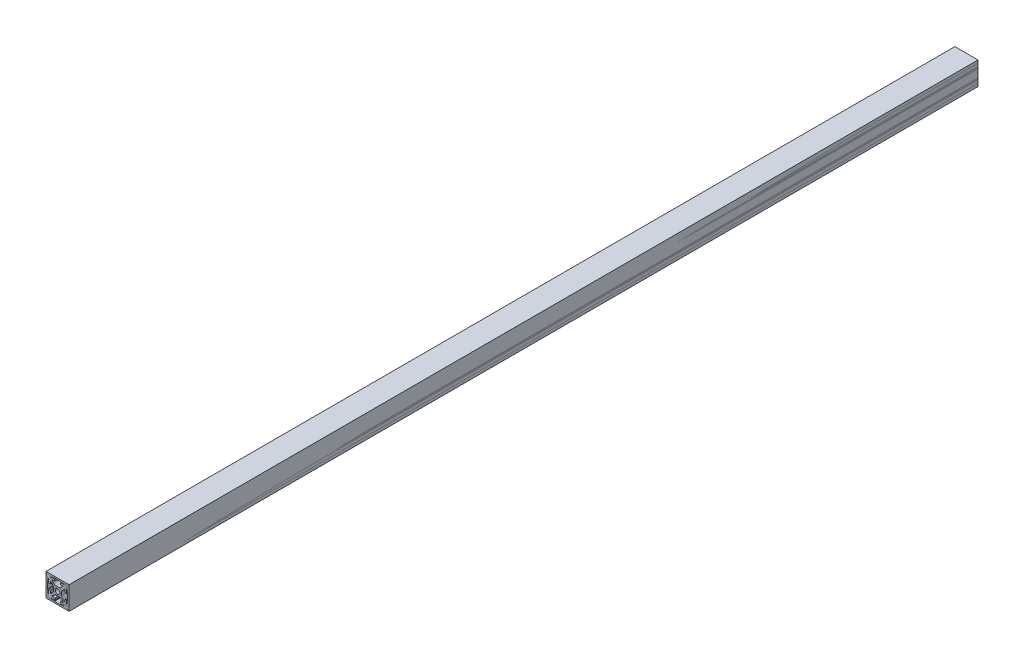
from build123d import *

# Parameters (mm, degrees)
SKETCH_2020_R       = 2.5
BOSS_EXTRUDE1_DEPTH = 1000
SKETCH2_R           = 2.6035
BOSS_EXTRUDE2_DEPTH = 1000
SKETCH3_W           = 25.4
SKETCH3_H           = 25.4
SKETCH3_W_2         = 22.225
SKETCH3_H_2         = 22.225
BOSS_EXTRUDE3_DEPTH = 1000


with BuildPart() as part:
    # 2020 → Boss-Extrude1 (new body)
    with BuildSketch(Plane.XY):
        with BuildLine():
            Line((8.25, 3), (9.75, 3))
            ThreePointArc((9.75, 3), (9.926776695, 3.073223305), (10, 3.25))
            Line((10, 3.25), (10, 9))
            ThreePointArc((10, 9), (9.707106781, 9.707106781), (9, 10))
            Line((9, 10), (3.25, 10))
            ThreePointArc((3.25, 10), (3.073223305, 9.926776695), (3, 9.75))
            Line((3, 9.75), (3, 8.25))
            ThreePointArc((3, 8.25), (3.073223305, 8.073223305), (3.25, 8))
            Line((3.25, 8), (5.75, 8))
            ThreePointArc((5.75, 8), (5.926776695, 7.926776695), (6, 7.75))
            Line((6, 7.75), (6, 7.164213562))
            ThreePointArc((6, 7.164213562), (5.980969883, 7.068542704), (5.926776695, 6.987436867))
            Line((5.926776695, 6.987436867), (3.085786438, 4.146446609))
            ThreePointArc((3.085786438, 4.146446609), (2.923574763, 4.038060234), (2.732233047, 4))
            Line((2.732233047, 4), (-2.732233047, 4))
            ThreePointArc((-2.732233047, 4), (-2.923574763, 4.038060234), (-3.085786438, 4.146446609))
            Line((-3.085786438, 4.146446609), (-5.926776695, 6.987436867))
            ThreePointArc((-5.926776695, 6.987436867), (-5.980969883, 7.068542704), (-6, 7.164213562))
            Line((-6, 7.164213562), (-6, 7.75))
            ThreePointArc((-6, 7.75), (-5.926776695, 7.926776695), (-5.75, 8))
            Line((-5.75, 8), (-3.25, 8))
            ThreePointArc((-3.25, 8), (-3.073223305, 8.073223305), (-3, 8.25))
            Line((-3, 8.25), (-3, 9.75))
            ThreePointArc((-3, 9.75), (-3.073223305, 9.926776695), (-3.25, 10))
            Line((-3.25, 10), (-9, 10))
            ThreePointArc((-9, 10), (-9.707106781, 9.707106781), (-10, 9))
            Line((-10, 9), (-10, 3.25))
            ThreePointArc((-10, 3.25), (-9.926776695, 3.073223305), (-9.75, 3))
            Line((-9.75, 3), (-8.25, 3))
            ThreePointArc((-8.25, 3), (-8.073223305, 3.073223305), (-8, 3.25))
            Line((-8, 3.25), (-8, 5.75))
            ThreePointArc((-8, 5.75), (-7.926776695, 5.926776695), (-7.75, 6))
            Line((-7.75, 6), (-7.164213562, 6))
            ThreePointArc((-7.164213562, 6), (-7.068542704, 5.980969883), (-6.987436867, 5.926776695))
            Line((-6.987436867, 5.926776695), (-4.146446609, 3.085786438))
            ThreePointArc((-4.146446609, 3.085786438), (-4.038060234, 2.923574763), (-4, 2.732233047))
            Line((-4, 2.732233047), (-4, -2.732233047))
            ThreePointArc((-4, -2.732233047), (-4.038060234, -2.923574763), (-4.146446609, -3.085786438))
            Line((-4.146446609, -3.085786438), (-6.987436867, -5.926776695))
            ThreePointArc((-6.987436867, -5.926776695), (-7.068542704, -5.980969883), (-7.164213562, -6))
            Line((-7.164213562, -6), (-7.75, -6))
            ThreePointArc((-7.75, -6), (-7.926776695, -5.926776695), (-8, -5.75))
            Line((-8, -5.75), (-8, -3.25))
            ThreePointArc((-8, -3.25), (-8.073223305, -3.073223305), (-8.25, -3))
            Line((-8.25, -3), (-9.75, -3))
            ThreePointArc((-9.75, -3), (-9.926776695, -3.073223305), (-10, -3.25))
            Line((-10, -3.25), (-10, -9))
            ThreePointArc((-10, -9), (-9.707106781, -9.707106781), (-9, -10))
            Line((-9, -10), (-3.25, -10))
            ThreePointArc((-3.25, -10), (-3.073223305, -9.926776695), (-3, -9.75))
            Line((-3, -9.75), (-3, -8.25))
            ThreePointArc((-3, -8.25), (-3.073223305, -8.073223305), (-3.25, -8))
            Line((-3.25, -8), (-5.75, -8))
            ThreePointArc((-5.75, -8), (-5.926776695, -7.926776695), (-6, -7.75))
            Line((-6, -7.75), (-6, -7.164213562))
            ThreePointArc((-6, -7.164213562), (-5.980969883, -7.068542704), (-5.926776695, -6.987436867))
            Line((-5.926776695, -6.987436867), (-3.085786438, -4.146446609))
            ThreePointArc((-3.085786438, -4.146446609), (-2.923574763, -4.038060234), (-2.732233047, -4))
            Line((-2.732233047, -4), (2.732233047, -4))
            ThreePointArc((2.732233047, -4), (2.923574763, -4.038060234), (3.085786438, -4.146446609))
            Line((3.085786438, -4.146446609), (5.926776695, -6.987436867))
            ThreePointArc((5.926776695, -6.987436867), (5.980969883, -7.068542704), (6, -7.164213562))
            Line((6, -7.164213562), (6, -7.75))
            ThreePointArc((6, -7.75), (5.926776695, -7.926776695), (5.75, -8))
            Line((5.75, -8), (3.25, -8))
            ThreePointArc((3.25, -8), (3.073223305, -8.073223305), (3, -8.25))
            Line((3, -8.25), (3, -9.75))
            ThreePointArc((3, -9.75), (3.073223305, -9.926776695), (3.25, -10))
            Line((3.25, -10), (9, -10))
            ThreePointArc((9, -10), (9.707106781, -9.707106781), (10, -9))
            Line((10, -9), (10, -3.25))
            ThreePointArc((10, -3.25), (9.926776695, -3.073223305), (9.75, -3))
            Line((9.75, -3), (8.25, -3))
            ThreePointArc((8.25, -3), (8.073223305, -3.073223305), (8, -3.25))
            Line((8, -3.25), (8, -5.75))
            ThreePointArc((8, -5.75), (7.926776695, -5.926776695), (7.75, -6))
            Line((7.75, -6), (7.164213562, -6))
            ThreePointArc((7.164213562, -6), (7.068542704, -5.980969883), (6.987436867, -5.926776695))
            Line((6.987436867, -5.926776695), (4.146446609, -3.085786438))
            ThreePointArc((4.146446609, -3.085786438), (4.038060234, -2.923574763), (4, -2.732233047))
            Line((4, -2.732233047), (4, 2.732233047))
            ThreePointArc((4, 2.732233047), (4.038060234, 2.923574763), (4.146446609, 3.085786438))
            Line((4.146446609, 3.085786438), (6.987436867, 5.926776695))
            ThreePointArc((6.987436867, 5.926776695), (7.068542704, 5.980969883), (7.164213562, 6))
            Line((7.164213562, 6), (7.75, 6))
            ThreePointArc((7.75, 6), (7.926776695, 5.926776695), (8, 5.75))
            Line((8, 5.75), (8, 3.25))
            ThreePointArc((8, 3.25), (8.073223305, 3.073223305), (8.25, 3))
        make_face()
        Circle(SKETCH_2020_R, mode=Mode.SUBTRACT)
    extrude(amount=BOSS_EXTRUDE1_DEPTH)


with BuildPart() as body_2:
    # Sketch2 → Boss-Extrude2 (new body)
    with BuildSketch(Plane.XY):
        with BuildLine():
            Line((-1.709253557, -4.4958), (1.709253557, -4.4958))
            ThreePointArc((1.709253557, -4.4958), (2.922935876, -4.736928798), (3.95226937, -5.423689619))
            Line((3.95226937, -5.423689619), (7.179652728, -8.645192207))
            ThreePointArc((7.179652728, -8.645192207), (7.414733441, -9.822812921), (6.41641086, -10.4902))
            Line((6.41641086, -10.4902), (4.28752, -10.4902))
            ThreePointArc((4.28752, -10.4902), (3.545750844, -10.797450844), (3.2385, -11.53922))
            Line((3.2385, -11.53922), (3.2385, -11.65098))
            ThreePointArc((3.2385, -11.65098), (3.545750844, -12.392749156), (4.28752, -12.7))
            Line((4.28752, -12.7), (5.3171344, -12.7))
            ThreePointArc((5.3171344, -12.7), (5.8251344, -12.192), (6.3331344, -12.7))
            Line((6.3331344, -12.7), (9.5504, -12.7))
            ThreePointArc((9.5504, -12.7), (10.058323491, -12.192000006), (10.566399977, -12.699846982))
            ThreePointArc((10.566399977, -12.699846982), (12.082522516, -12.082522516), (12.699846982, -10.566399977))
            ThreePointArc((12.699846982, -10.566399977), (12.192000006, -10.058323491), (12.7, -9.5504))
            Line((12.7, -9.5504), (12.7, -6.3330836))
            ThreePointArc((12.7, -6.3330836), (12.192, -5.8250836), (12.7, -5.3170836))
            Line((12.7, -5.3170836), (12.7, -4.287470133))
            ThreePointArc((12.7, -4.287470133), (12.392749156, -3.545700977), (11.65098, -3.238450133))
            Line((11.65098, -3.238450133), (11.53922, -3.238450133))
            ThreePointArc((11.53922, -3.238450133), (10.797450844, -3.545700977), (10.4902, -4.287470133))
            Line((10.4902, -4.287470133), (10.4902, -6.402089023))
            ThreePointArc((10.4902, -6.402089023), (9.856394933, -7.351113629), (8.736962546, -7.129240479))
            Line((8.736962546, -7.129240479), (5.440484187, -3.838768792))
            ThreePointArc((5.440484187, -3.838768792), (4.75073678, -2.808015636), (4.5085, -1.591658411))
            Line((4.5085, -1.591658411), (4.5085, 1.591658411))
            ThreePointArc((4.5085, 1.591658411), (4.75073678, 2.808015636), (5.440484187, 3.838768792))
            Line((5.440484187, 3.838768792), (8.736962546, 7.129240479))
            ThreePointArc((8.736962546, 7.129240479), (9.856394933, 7.351113629), (10.4902, 6.402089023))
            Line((10.4902, 6.402089023), (10.4902, 4.287470133))
            ThreePointArc((10.4902, 4.287470133), (10.797450844, 3.545700977), (11.53922, 3.238450133))
            Line((11.53922, 3.238450133), (11.65098, 3.238450133))
            ThreePointArc((11.65098, 3.238450133), (12.392749156, 3.545700977), (12.7, 4.287470133))
            Line((12.7, 4.287470133), (12.7, 5.3171344))
            ThreePointArc((12.7, 5.3171344), (12.192, 5.8251344), (12.7, 6.3331344))
            Line((12.7, 6.3331344), (12.7, 9.5504))
            ThreePointArc((12.7, 9.5504), (12.192000006, 10.058323491), (12.699846982, 10.566399977))
            ThreePointArc((12.699846982, 10.566399977), (12.082522516, 12.082522516), (10.566399977, 12.699846982))
            ThreePointArc((10.566399977, 12.699846982), (10.058323491, 12.192000006), (9.5504, 12.7))
            Line((9.5504, 12.7), (6.3330836, 12.7))
            ThreePointArc((6.3330836, 12.7), (5.8250836, 12.192), (5.3170836, 12.7))
            Line((5.3170836, 12.7), (4.2874692, 12.7))
            ThreePointArc((4.2874692, 12.7), (3.545700044, 12.392749156), (3.2384492, 11.65098))
            Line((3.2384492, 11.65098), (3.2384492, 11.53922))
            ThreePointArc((3.2384492, 11.53922), (3.545700044, 10.797450844), (4.2874692, 10.4902))
            Line((4.2874692, 10.4902), (6.476774195, 10.4902))
            ThreePointArc((6.476774195, 10.4902), (7.43216212, 9.851515102), (7.207191475, 8.724540082))
            Line((7.207191475, 8.724540082), (3.900315394, 5.423689619))
            ThreePointArc((3.900315394, 5.423689619), (2.8709819, 4.736928798), (1.657299581, 4.4958))
            Line((1.657299581, 4.4958), (-1.657299581, 4.4958))
            ThreePointArc((-1.657299581, 4.4958), (-2.8709819, 4.736928798), (-3.900315394, 5.423689619))
            Line((-3.900315394, 5.423689619), (-7.207191475, 8.724540082))
            ThreePointArc((-7.207191475, 8.724540082), (-7.43216212, 9.851515102), (-6.476774195, 10.4902))
            Line((-6.476774195, 10.4902), (-4.2874692, 10.4902))
            ThreePointArc((-4.2874692, 10.4902), (-3.545700044, 10.797450844), (-3.2384492, 11.53922))
            Line((-3.2384492, 11.53922), (-3.2384492, 11.65098))
            ThreePointArc((-3.2384492, 11.65098), (-3.545700044, 12.392749156), (-4.2874692, 12.7))
            Line((-4.2874692, 12.7), (-5.3170836, 12.7))
            ThreePointArc((-5.3170836, 12.7), (-5.8250836, 12.192), (-6.3330836, 12.7))
            Line((-6.3330836, 12.7), (-9.5504, 12.7))
            ThreePointArc((-9.5504, 12.7), (-10.058323491, 12.192000006), (-10.566399977, 12.699846982))
            ThreePointArc((-10.566399977, 12.699846982), (-12.082522516, 12.082522516), (-12.699846982, 10.566399977))
            ThreePointArc((-12.699846982, 10.566399977), (-12.192000006, 10.058323491), (-12.7, 9.5504))
            Line((-12.7, 9.5504), (-12.7, 6.3331344))
            ThreePointArc((-12.7, 6.3331344), (-12.192, 5.8251344), (-12.7, 5.3171344))
            Line((-12.7, 5.3171344), (-12.7, 4.287470133))
            ThreePointArc((-12.7, 4.287470133), (-12.392749156, 3.545700977), (-11.65098, 3.238450133))
            Line((-11.65098, 3.238450133), (-11.53922, 3.238450133))
            ThreePointArc((-11.53922, 3.238450133), (-10.797450844, 3.545700977), (-10.4902, 4.287470133))
            Line((-10.4902, 4.287470133), (-10.4902, 6.402089023))
            ThreePointArc((-10.4902, 6.402089023), (-9.856394933, 7.351113629), (-8.736962546, 7.129240479))
            Line((-8.736962546, 7.129240479), (-5.440484187, 3.838768792))
            ThreePointArc((-5.440484187, 3.838768792), (-4.75073678, 2.808015636), (-4.5085, 1.591658411))
            Line((-4.5085, 1.591658411), (-4.5085, -1.591658411))
            ThreePointArc((-4.5085, -1.591658411), (-4.75073678, -2.808015636), (-5.440484187, -3.838768792))
            Line((-5.440484187, -3.838768792), (-8.736962546, -7.129240479))
            ThreePointArc((-8.736962546, -7.129240479), (-9.856394933, -7.351113629), (-10.4902, -6.402089023))
            Line((-10.4902, -6.402089023), (-10.4902, -4.287470133))
            ThreePointArc((-10.4902, -4.287470133), (-10.797450844, -3.545700977), (-11.53922, -3.238450133))
            Line((-11.53922, -3.238450133), (-11.65098, -3.238450133))
            ThreePointArc((-11.65098, -3.238450133), (-12.392749156, -3.545700977), (-12.7, -4.287470133))
            Line((-12.7, -4.287470133), (-12.7, -5.3170836))
            ThreePointArc((-12.7, -5.3170836), (-12.192, -5.8250836), (-12.7, -6.3330836))
            Line((-12.7, -6.3330836), (-12.7, -9.5504))
            ThreePointArc((-12.7, -9.5504), (-12.192000006, -10.058323491), (-12.699846982, -10.566399977))
            ThreePointArc((-12.699846982, -10.566399977), (-12.082522516, -12.082522516), (-10.566399977, -12.699846982))
            ThreePointArc((-10.566399977, -12.699846982), (-10.058323491, -12.192000006), (-9.5504, -12.7))
            Line((-9.5504, -12.7), (-6.3331344, -12.7))
            ThreePointArc((-6.3331344, -12.7), (-5.8251344, -12.192), (-5.3171344, -12.7))
            Line((-5.3171344, -12.7), (-4.28752, -12.7))
            ThreePointArc((-4.28752, -12.7), (-3.545750844, -12.392749156), (-3.2385, -11.65098))
            Line((-3.2385, -11.65098), (-3.2385, -11.53922))
            ThreePointArc((-3.2385, -11.53922), (-3.545750844, -10.797450844), (-4.28752, -10.4902))
            Line((-4.28752, -10.4902), (-6.41641086, -10.4902))
            ThreePointArc((-6.41641086, -10.4902), (-7.414733441, -9.822812921), (-7.179652728, -8.645192207))
            Line((-7.179652728, -8.645192207), (-3.95226937, -5.423689619))
            ThreePointArc((-3.95226937, -5.423689619), (-2.922935876, -4.736928798), (-1.709253557, -4.4958))
        make_face()
        Circle(SKETCH2_R, mode=Mode.SUBTRACT)
    extrude(amount=BOSS_EXTRUDE2_DEPTH)


with BuildPart() as body_3:
    # Sketch3 → Boss-Extrude3 (new body)
    with BuildSketch(Plane.XY):
        Rectangle(SKETCH3_W, SKETCH3_H)
        Rectangle(SKETCH3_W_2, SKETCH3_H_2, mode=Mode.SUBTRACT)
    extrude(amount=BOSS_EXTRUDE3_DEPTH)


solid = Compound([part.part, body_2.part, body_3.part])
